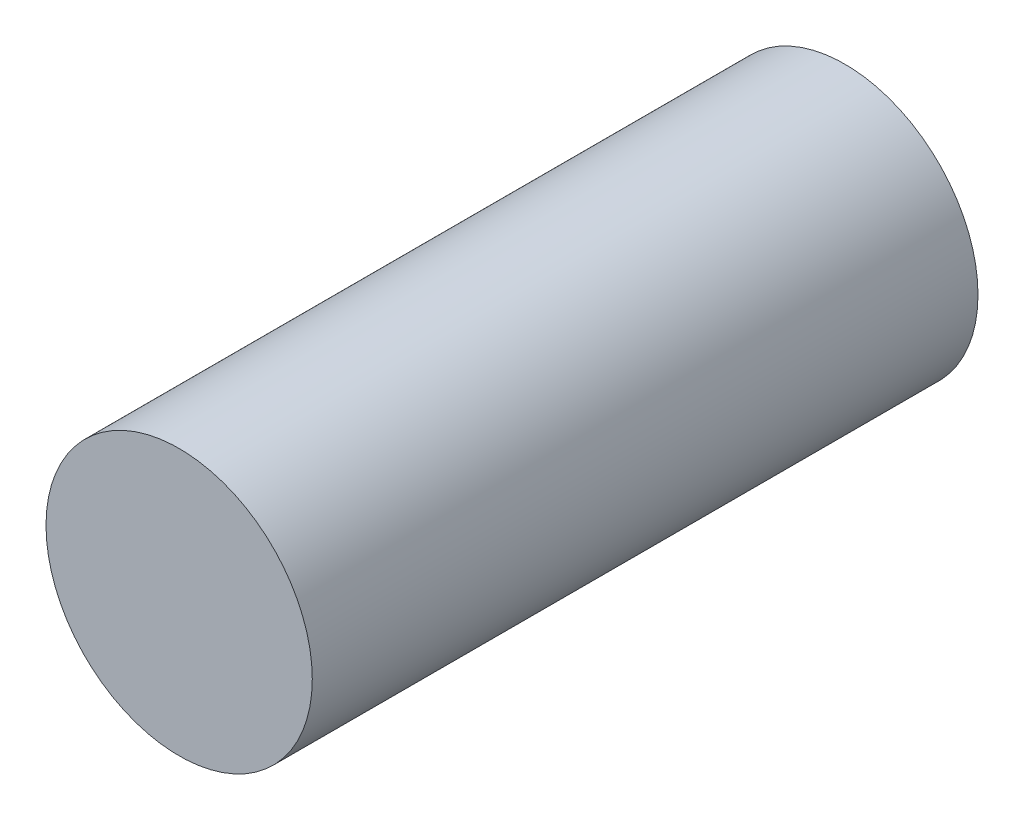
from build123d import *

# Parameters (mm, degrees)
SKETCH1_R           = 25.4
BOSS_EXTRUDE1_DEPTH = 127


with BuildPart() as part:
    # Sketch1 → Boss-Extrude1 (new body)
    with BuildSketch(Plane.XY):
        Circle(SKETCH1_R)
    extrude(amount=BOSS_EXTRUDE1_DEPTH)


solid = part.part
